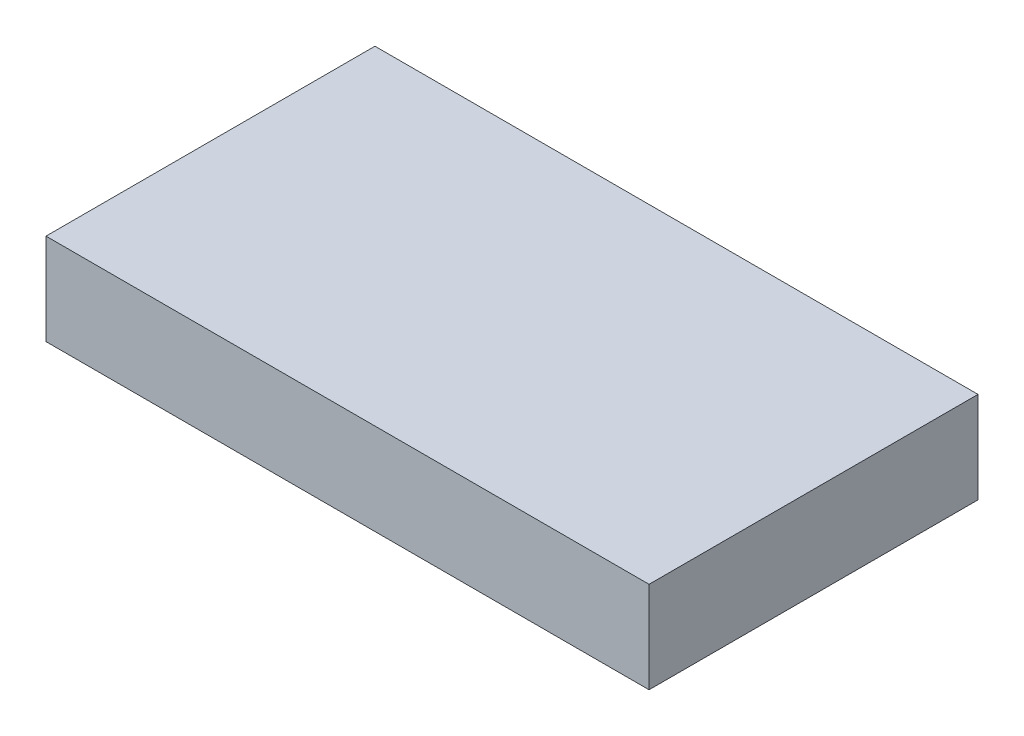
from build123d import *

# Parameters (mm, degrees)
SKETCH1_W           = 66
SKETCH1_H           = 36
BOSS_EXTRUDE1_DEPTH = 10


with BuildPart() as part:
    # Sketch1 → Boss-Extrude1 (new body)
    with BuildSketch(Plane(origin=(0, 0, 0), x_dir=(1, 0, 0), z_dir=(0, 1, 0))):
        with Locations((33, 18)):
            Rectangle(SKETCH1_W, SKETCH1_H)
    extrude(amount=BOSS_EXTRUDE1_DEPTH)


solid = part.part
